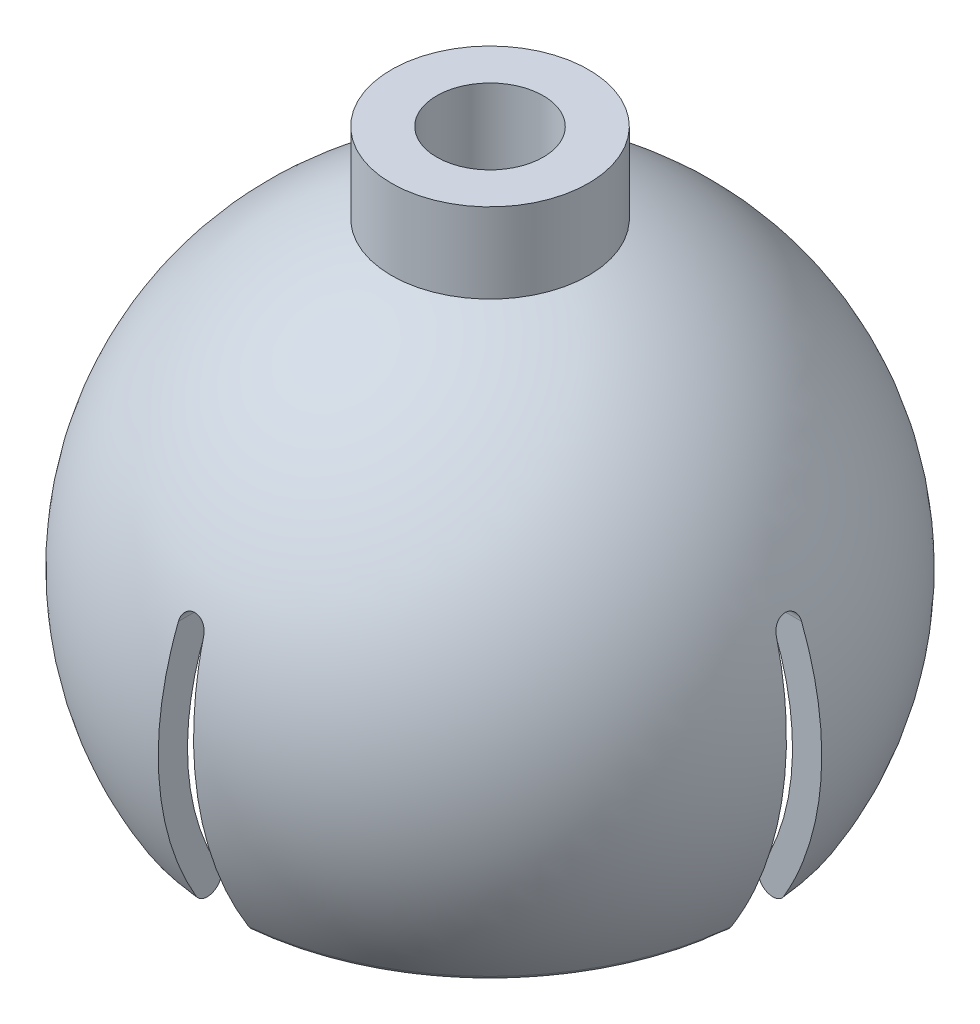
from build123d import *

# Parameters (mm, degrees)
SKETCH1_R           = 3.7
SKETCH1_R_2         = 2
BOSS_EXTRUDE1_DEPTH = 3
CUT_EXTRUDE1_DEPTH  = 12.79718581
CIRPATTERN1_COUNT   = 4


with BuildPart() as part:
    # Sketch1 → Boss-Extrude1 (new body)
    with BuildSketch(Plane(origin=(0, 0, 0), x_dir=(1, 0, 0), z_dir=(0, 1, 0))):
        Circle(SKETCH1_R)
        Circle(SKETCH1_R_2, mode=Mode.SUBTRACT)
    extrude(amount=BOSS_EXTRUDE1_DEPTH)

    # Sketch2 → Revolve1 (revolve)
    with BuildSketch(Plane(origin=(0, 0, 0), x_dir=(0, 0, -1), z_dir=(1, 0, 0))):
        with BuildLine():
            Line((0, 0), (3.7, 0))
            ThreePointArc((3.7, 0), (11.06716667, -7.226007618), (10.1, -17.5))
            ThreePointArc((10.1, -17.5), (9.414366099, -17.672933956), (9.241432142, -16.987300055))
            ThreePointArc((9.241432142, -16.987300055), (9.596057225, -7.167858517), (1.5, -1.6))
            Line((1.5, -1.6), (1.5, -2.8))
            Line((1.5, -2.8), (0, -2.8))
            Line((0, -2.8), (0, 0))
        make_face()
    revolve(axis=Axis((0, 0, 0), (0, -1, 0)))

    # Sketch3 → Cut-Extrude1 (cut, symmetric)
    with BuildSketch(Plane(origin=(0, 0, 0), x_dir=(0, 0, -1), z_dir=(1, 0, 0))):
        with BuildLine():
            Line((-1, -17.743650027), (1, -17.743650027))
            Line((1, -17.743650027), (0.474618631, -7.718776319))
            ThreePointArc((0.474618631, -7.718776319), (0, -7.268380055), (-0.474618631, -7.718776319))
            Line((-0.474618631, -7.718776319), (-1, -17.743650027))
        make_face()
    cut_extrude1 = extrude(amount=CUT_EXTRUDE1_DEPTH, both=True, mode=Mode.SUBTRACT)

    # CirPattern1: Cut-Extrude1 ×4 about axis
    cirpattern1_axis = Axis((0, 0, 0), (0, 1, 0))
    for i in range(1, CIRPATTERN1_COUNT):
        add(cut_extrude1.rotate(cirpattern1_axis, i * 360 / CIRPATTERN1_COUNT), mode=Mode.SUBTRACT)


solid = part.part
